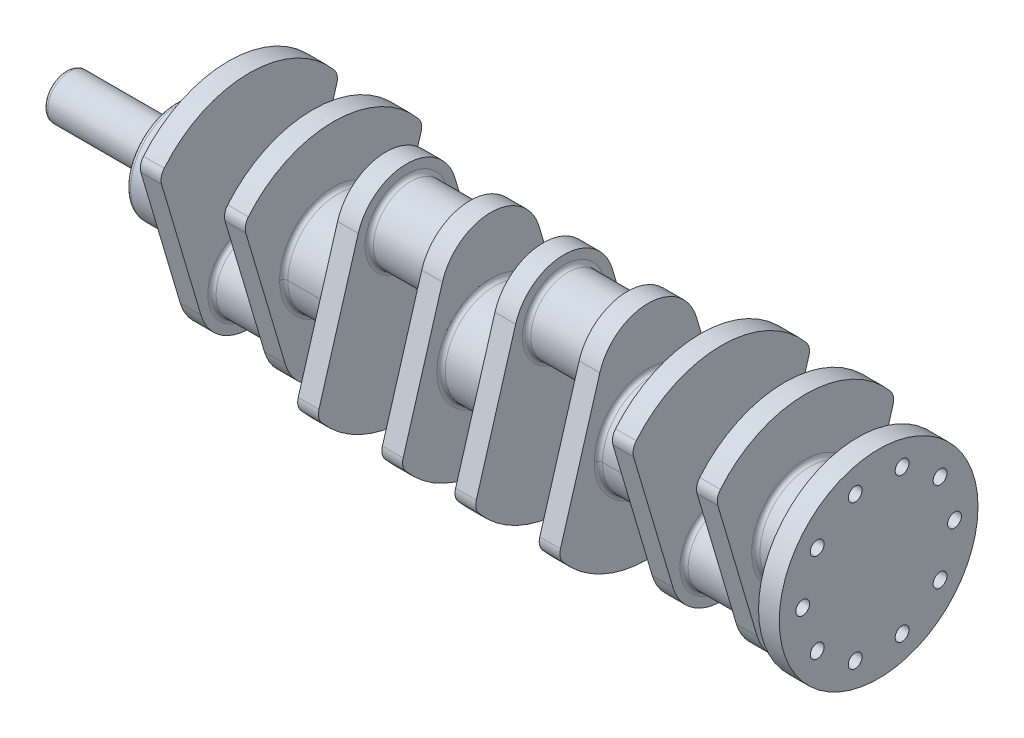
from build123d import *

# Parameters (mm, degrees)
SKETCH1_R             = 36
BOSS_EXTRUDE1_DEPTH   = 38
SKETCH2_R             = 27
BOSS_EXTRUDE2_DEPTH   = 15
SKETCH2_2_R           = 27
BOSS_EXTRUDE3_DEPTH   = 61
BODY_MOVE_COPY1_ANGLE = 180
SKETCH3_R             = 72
SKETCH3_R_2           = 5
BOSS_EXTRUDE4_DEPTH   = 15
FILLET1_R             = 3
FILLET2_R             = 10
SKETCH4_R             = 16
BOSS_EXTRUDE5_DEPTH   = 80
FILLET3_R             = 3


with BuildPart() as part:
    # Sketch1 → Boss-Extrude1 (new body)
    with BuildSketch(Plane(origin=(0, 0, 0), x_dir=(0, 0, -1), z_dir=(1, 0, 0))):
        Circle(SKETCH1_R)
    extrude(amount=BOSS_EXTRUDE1_DEPTH)

    # Sketch2 → Boss-Extrude2 (add)
    with BuildSketch(Plane(origin=(38, 0, 0), x_dir=(0, 0, -1), z_dir=(1, 0, 0))):
        with BuildLine():
            Line((-34.996920323, -54.366560082), (-64.940172867, 46.720166396))
            ThreePointArc((-64.940172867, 46.720166396), (0, 80), (64.940172867, 46.720166396))
            Line((64.940172867, 46.720166396), (34.996920323, -54.366560082))
            ThreePointArc((34.996920323, -54.366560082), (0, -80.5), (-34.996920323, -54.366560082))
        make_face()
        with Locations((0, -44)):
            Circle(SKETCH2_R, mode=Mode.SUBTRACT)
    extrude(amount=BOSS_EXTRUDE2_DEPTH)

    # Sketch2_2 → Boss-Extrude3 (add)
    with BuildSketch(Plane(origin=(38, 0, 0), x_dir=(0, 0, -1), z_dir=(1, 0, 0))):
        with Locations((0, -44)):
            Circle(SKETCH2_2_R)
    extrude(amount=BOSS_EXTRUDE3_DEPTH)

    # Mirror1: part across plane


with BuildPart() as part_1:
    add(part.part)
    add(part.part.mirror(Plane(origin=(76, 0, 0), x_dir=(0, 0, 1), z_dir=(1, 0, 0))))


with BuildPart() as body_2:
    # Mirror2: mirrored copy
    add(part_1.part.mirror(Plane(origin=(133, 0, 0), x_dir=(0, 0, 1), z_dir=(1, 0, 0))))


with BuildPart() as body_2_1:
    # Body-Move_Copy1: moved
    add(body_2.part.rotate(Axis((0, -0.25, 0), (1, 0, 0)), BODY_MOVE_COPY1_ANGLE))


with BuildPart() as body_3:
    # Mirror3: mirrored copy
    add(part_1.part.mirror(Plane(origin=(247, 0, 0), x_dir=(0, 0, 1), z_dir=(1, 0, 0))))


with BuildPart() as body_4:
    # Mirror3 2: mirrored copy
    add(body_2_1.part.mirror(Plane(origin=(247, 0, 0), x_dir=(0, 0, 1), z_dir=(1, 0, 0))))


with BuildPart() as part_2:
    add(part_1.part)

    # Combine1: union body 2, body 4, body 3
    add(body_2_1.part)
    add(body_4.part)
    add(body_3.part)

    # Sketch3 → Boss-Extrude4 (add)
    with BuildSketch(Plane(origin=(494, 0, 0), x_dir=(0, 0, -1), z_dir=(1, 0, 0))):
        Circle(SKETCH3_R)
        with Locations((55, 0)):
            Circle(SKETCH3_R_2, mode=Mode.SUBTRACT)
        with Locations((44.495934691, -32.328188876)):
            Circle(SKETCH3_R_2, mode=Mode.SUBTRACT)
        with Locations((16.995934691, -52.308108396)):
            Circle(SKETCH3_R_2, mode=Mode.SUBTRACT)
        with Locations((-16.995934691, -52.308108396)):
            Circle(SKETCH3_R_2, mode=Mode.SUBTRACT)
        with Locations((-44.495934691, -32.328188876)):
            Circle(SKETCH3_R_2, mode=Mode.SUBTRACT)
        with Locations((-55, 0)):
            Circle(SKETCH3_R_2, mode=Mode.SUBTRACT)
        with Locations((-44.495934691, 32.328188876)):
            Circle(SKETCH3_R_2, mode=Mode.SUBTRACT)
        with Locations((-16.995934691, 52.308108396)):
            Circle(SKETCH3_R_2, mode=Mode.SUBTRACT)
        with Locations((16.995934691, 52.308108396)):
            Circle(SKETCH3_R_2, mode=Mode.SUBTRACT)
        with Locations((44.495934691, 32.328188876)):
            Circle(SKETCH3_R_2, mode=Mode.SUBTRACT)
    extrude(amount=BOSS_EXTRUDE4_DEPTH)

    # Fillet1
    fillet1_edges = [part_2.edges().sort_by_distance(p)[0] for p in [
        (53, -44, 27),
        (0, 0, 36),
        (99, -44, 27),
        (38, 0, 36),
        (114, 36, 0),
        (114, -36.5, 0),
        (152, 36, 0),
        (133, -0.25, -35.999131934),
        (133, -0.25, 35.999131934),
        (228, -0.5, -36),
        (213, 43.5, -27),
        (167, 43.5, -27),
        (152, -36.5, 0),
        (342, -36.5, 0),
        (266, -0.5, -36),
        (281, 43.5, -27),
        (327, 43.5, -27),
        (342, 36, 0),
        (361, -0.25, 35.999131934),
        (361, -0.25, -35.999131934),
        (456, 0, 36),
        (494, 0, 36),
        (441, -44, 27),
        (395, -44, 27),
        (380, 36, 0),
        (380, -36.5, 0),
    ]]
    fillet(fillet1_edges, radius=FILLET1_R)

    # Fillet2
    fillet2_edges = [part_2.edges().sort_by_distance(p)[0] for p in [
        (45.5, 46.720166396, 64.940172867),
        (106.5, 46.720166396, -64.940172867),
        (106.5, 46.720166396, 64.940172867),
        (220.5, -47.220166396, 64.940172867),
        (220.5, -47.220166396, -64.940172867),
        (159.5, -47.220166396, 64.940172867),
        (159.5, -47.220166396, -64.940172867),
        (273.5, -47.220166396, 64.940172867),
        (273.5, -47.220166396, -64.940172867),
        (334.5, -47.220166396, 64.940172867),
        (334.5, -47.220166396, -64.940172867),
        (448.5, 46.720166396, -64.940172867),
        (448.5, 46.720166396, 64.940172867),
        (387.5, 46.720166396, -64.940172867),
        (387.5, 46.720166396, 64.940172867),
        (45.5, 46.720166396, -64.940172867),
    ]]
    fillet(fillet2_edges, radius=FILLET2_R)

    # Sketch4 → Boss-Extrude5 (add)
    with BuildSketch(Plane.ZY):
        Circle(SKETCH4_R)
    extrude(amount=BOSS_EXTRUDE5_DEPTH)

    # Fillet3
    fillet3_edges = [part_2.edges().sort_by_distance(p)[0] for p in [
        (0, 0, -16),
        (-80, 0, -16),
    ]]
    fillet(fillet3_edges, radius=FILLET3_R)


solid = part_2.part
